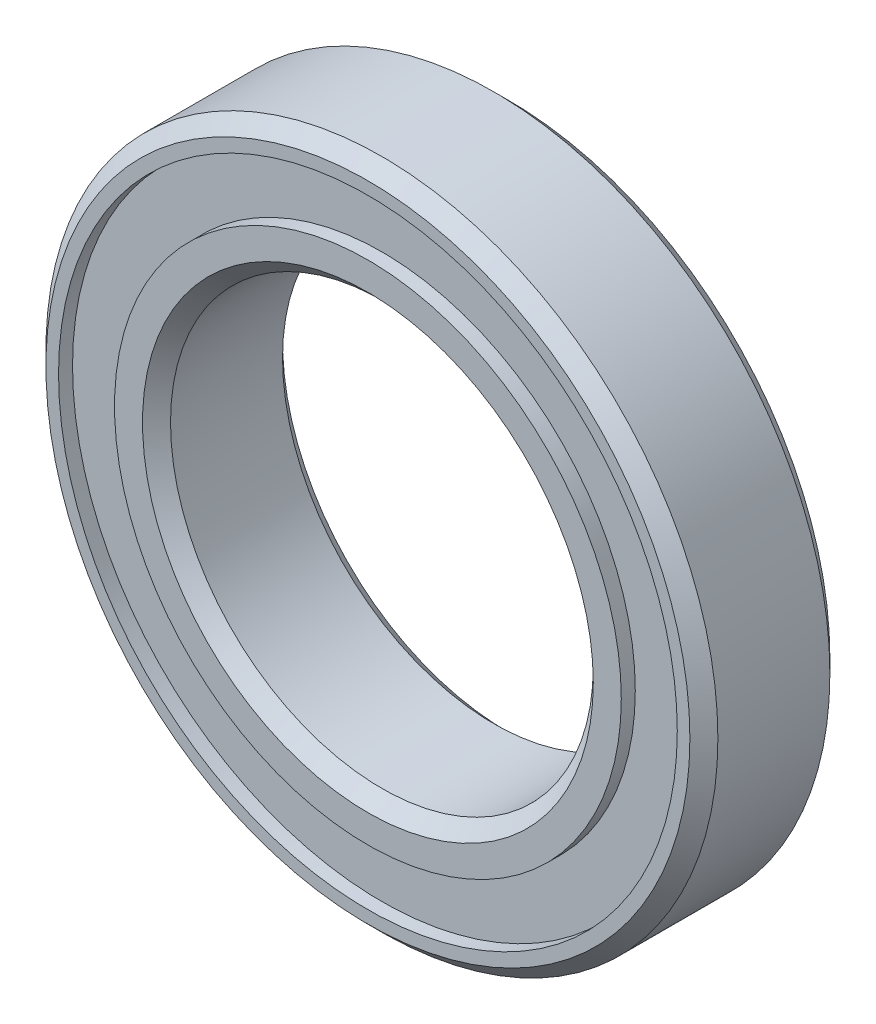
from build123d import *

# Parameters (mm, degrees)
ESBO_O1_R                = 12
ESBO_O1_R_2              = 7.55
RESSALTO_EXTRUS_O1_DEPTH = 5
ESBO_O2_R                = 11.05
ESBO_O2_R_2              = 9.05
CORTE_EXTRUS_O1_DEPTH    = 0.5
ESBO_O3_R                = 11.05
ESBO_O3_R_2              = 9.05
CORTE_EXTRUS_O2_DEPTH    = 0.5
CHANFRO1_SIZE            = 0.5


with BuildPart() as part:
    # Esboço1 → Ressalto-extrusão1 (new body)
    with BuildSketch(Plane.XY):
        Circle(ESBO_O1_R)
        Circle(ESBO_O1_R_2, mode=Mode.SUBTRACT)
    extrude(amount=RESSALTO_EXTRUS_O1_DEPTH)

    # Esboço2 → Corte-extrusão1 (cut)
    with BuildSketch(Plane.XY.offset(5)):
        Circle(ESBO_O2_R)
        Circle(ESBO_O2_R_2, mode=Mode.SUBTRACT)
    extrude(amount=-CORTE_EXTRUS_O1_DEPTH, mode=Mode.SUBTRACT)

    # Esboço3 → Corte-extrusão2 (cut)
    with BuildSketch(Plane(origin=(0, 0, 0), x_dir=(-1, 0, 0), z_dir=(0, 0, -1))):
        Circle(ESBO_O3_R)
        Circle(ESBO_O3_R_2, mode=Mode.SUBTRACT)
    extrude(amount=-CORTE_EXTRUS_O2_DEPTH, mode=Mode.SUBTRACT)

    # Chanfro1
    chanfro1_edges = [part.edges().sort_by_distance(p)[0] for p in [
        (-12, 0, 0),
        (-12, 0, 5),
        (-7.55, 0, 0),
        (-7.55, 0, 5),
    ]]
    chamfer(chanfro1_edges, length=CHANFRO1_SIZE)


solid = part.part
